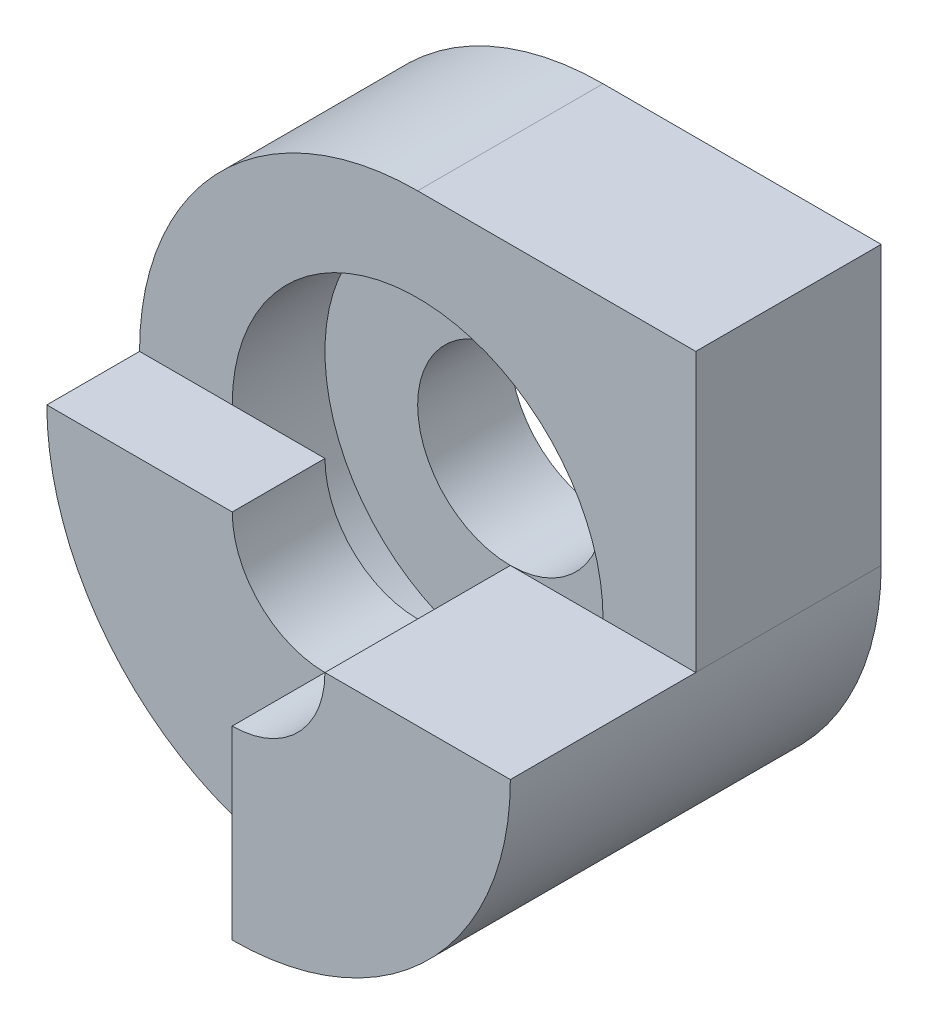
from build123d import *

# Parameters (mm, degrees)
SKETCH1_R           = 1
BOSS_EXTRUDE1_DEPTH = 2
SKETCH2_R           = 2
CUT_EXTRUDE1_DEPTH  = 1
BOSS_EXTRUDE2_DEPTH = 2
BOSS_EXTRUDE3_DEPTH = 1


with BuildPart() as part:
    # Sketch1 → Boss-Extrude1 (new body)
    with BuildSketch(Plane.XY):
        with BuildLine():
            Line((3, 0), (3, 3))
            Line((3, 3), (0, 3))
            ThreePointArc((0, 3), (-3, 0), (0, -3))
            ThreePointArc((0, -3), (2.121320344, -2.121320344), (3, 0))
        make_face()
        Circle(SKETCH1_R, mode=Mode.SUBTRACT)
    extrude(amount=BOSS_EXTRUDE1_DEPTH)

    # Sketch2 → Cut-Extrude1 (cut)
    with BuildSketch(Plane.XY.offset(2)):
        Circle(SKETCH2_R)
    extrude(amount=-CUT_EXTRUDE1_DEPTH, mode=Mode.SUBTRACT)

    # Sketch3 → Boss-Extrude2 (add)
    with BuildSketch(Plane.XY.offset(2)):
        with BuildLine():
            Line((0, -2), (0, -3))
            ThreePointArc((0, -3), (2.121320344, -2.121320344), (3, 0))
            Line((3, 0), (2, 0))
            Line((2, 0), (1, 0))
            ThreePointArc((1, 0), (0.707106781, -0.707106781), (0, -1))
            Line((0, -1), (0, -2))
        make_face()
    extrude(amount=BOSS_EXTRUDE2_DEPTH)

    # Sketch4 → Boss-Extrude3 (add)
    with BuildSketch(Plane.XY.offset(2)):
        with BuildLine():
            Line((-3, 0), (-2, 0))
            Line((-2, 0), (-1, 0))
            ThreePointArc((-1, 0), (-0.707106781, -0.707106781), (0, -1))
            Line((0, -1), (0, -2))
            Line((0, -2), (0, -3))
            ThreePointArc((0, -3), (-2.121320344, -2.121320344), (-3, 0))
        make_face()
    extrude(amount=BOSS_EXTRUDE3_DEPTH)


solid = part.part
